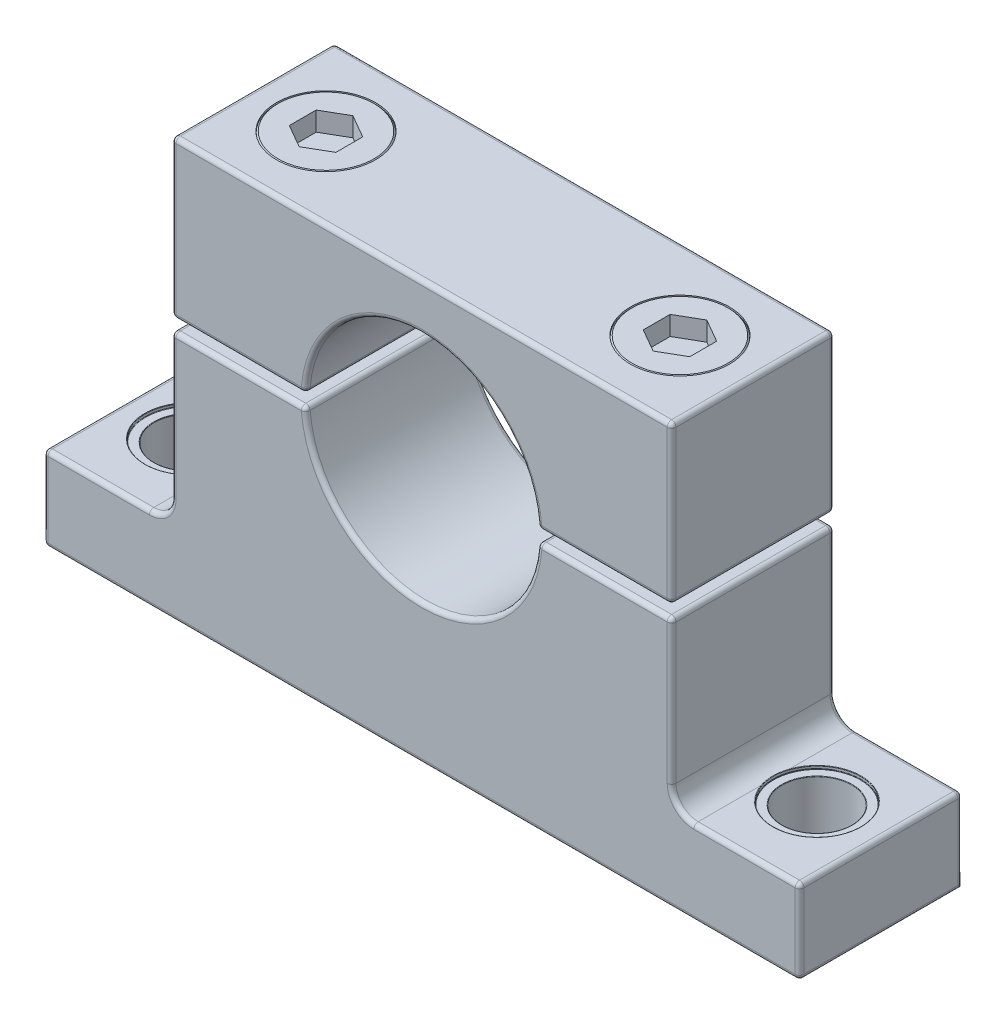
from build123d import *

# Parameters (mm, degrees)
BOSS_EXTRUDE1_DEPTH   = 14
BOSS_EXTRUDE1_2_DEPTH = 14
SKETCH4_R             = 3
CUT_EXTRUDE1_DEPTH    = 37
SKETCH8_R             = 3.762
CUT_EXTRUDE3_DEPTH    = 14.546
SKETCH10_R            = 2.754
CUT_EXTRUDE4_DEPTH    = 37
SKETCH12_R            = 4.2625
CUT_EXTRUDE5_DEPTH    = 5.015
CHAMFER1_SIZE         = 0.127
CUT_EXTRUDE6_DEPTH    = 1.65
FILLET1_R             = 0.381
FILLET2_R             = 0.381
FILLET3_R             = 0.0381


with BuildPart() as part:
    # Sketch3 → Boss-Extrude1 (new body)
    with BuildSketch(Plane.XY):
        with BuildLine():
            Line((-21.5, 36), (21.5, 36))
            Line((21.5, 36), (21.5, 22.508))
            Line((21.5, 22.508), (9.987088465, 22.508))
            ThreePointArc((9.987088465, 22.508), (0, 32), (-9.987088465, 22.508))
            Line((-9.987088465, 22.508), (-21.5, 22.508))
            Line((-21.5, 22.508), (-21.5, 36))
        make_face()
    extrude(amount=-BOSS_EXTRUDE1_DEPTH)


with BuildPart() as body_2:
    # Sketch3 → Boss-Extrude1 2 (new body)
    with BuildSketch(Plane.XY):
        with BuildLine():
            Line((-21.5, 21.492), (-21.5, 9.105))
            ThreePointArc((-21.5, 9.105), (-22.057961582, 7.757961582), (-23.405, 7.2))
            Line((-23.405, 7.2), (-32.5, 7.2))
            Line((-32.5, 7.2), (-32.5, 0))
            Line((-32.5, 0), (32.5, 0))
            Line((32.5, 0), (32.5, 7.2))
            Line((32.5, 7.2), (23.405, 7.2))
            ThreePointArc((23.405, 7.2), (22.057961582, 7.757961582), (21.5, 9.105))
            Line((21.5, 9.105), (21.5, 21.492))
            Line((21.5, 21.492), (9.987088465, 21.492))
            ThreePointArc((9.987088465, 21.492), (0, 12), (-9.987088465, 21.492))
            Line((-9.987088465, 21.492), (-21.5, 21.492))
        make_face()
    extrude(amount=-BOSS_EXTRUDE1_2_DEPTH)

    # Sketch4 → Cut-Extrude1 (cut, through all)
    with BuildSketch(Plane.XZ):
        with Locations((-27, -7)):
            Circle(SKETCH4_R)
        with Locations((27, -7)):
            Circle(SKETCH4_R)
    extrude(amount=-CUT_EXTRUDE1_DEPTH, mode=Mode.SUBTRACT)

    # Sketch8 → Cut-Extrude3 (cut)
    with BuildSketch(Plane(origin=(0, 21.492, 0), x_dir=(1, 0, 0), z_dir=(0, 1, 0))):
        with Locations((-27, 7)):
            Circle(SKETCH8_R)
        with Locations((27, 7)):
            Circle(SKETCH8_R)
    extrude(amount=-CUT_EXTRUDE3_DEPTH, mode=Mode.SUBTRACT)


with BuildPart() as cut_extrude4_tool:
    # Sketch10 → Cut-Extrude4 (new body, through all)
    with BuildSketch(Plane(origin=(0, 36, 0), x_dir=(1, 0, 0), z_dir=(0, 1, 0))):
        with Locations((15.218, 7)):
            Circle(SKETCH10_R)
        with Locations((-15.218, 7)):
            Circle(SKETCH10_R)
    extrude(amount=-CUT_EXTRUDE4_DEPTH)


with BuildPart() as part_1:
    add(part.part)

    # Cut-Extrude4: cut by cut_extrude4_tool
    add(cut_extrude4_tool.part, mode=Mode.SUBTRACT)

    # Sketch12 → Cut-Extrude5 (cut)
    with BuildSketch(Plane(origin=(0, 36, 0), x_dir=(1, 0, 0), z_dir=(0, 1, 0))):
        with Locations((15.218, 7)):
            Circle(SKETCH12_R)
        with Locations((-15.218, 7)):
            Circle(SKETCH12_R)
    extrude(amount=-CUT_EXTRUDE5_DEPTH, mode=Mode.SUBTRACT)

    # Fillet1
    fillet1_edges = [part_1.edges().sort_by_distance(p)[0] for p in [
        (0, 32, -14),
        (-21.5, 36, -7),
        (21.5, 36, -7),
        (21.5, 22.508, -7),
        (9.987088465, 22.508, -7),
        (-9.987088465, 22.508, -7),
        (-21.5, 22.508, -7),
        (15.743544232, 22.508, -14),
        (21.5, 29.254, -14),
        (0, 36, -14),
        (-21.5, 29.254, -14),
        (0, 36, 0),
        (21.5, 29.254, 0),
        (15.743544232, 22.508, 0),
        (-15.743544232, 22.508, -14),
        (0, 32, 0),
        (-15.743544232, 22.508, 0),
        (-21.5, 29.254, 0),
    ]]
    fillet(fillet1_edges, radius=FILLET1_R)


with BuildPart() as body_2_1:
    add(body_2.part)

    # Cut-Extrude4: cut by cut_extrude4_tool
    add(cut_extrude4_tool.part, mode=Mode.SUBTRACT)

    # Fillet2
    fillet2_edges = [body_2_1.edges().sort_by_distance(p)[0] for p in [
        (-22.057961582, 7.757961582, -14),
        (0, 12, 0),
        (15.743544232, 21.492, 0),
        (21.5, 15.2985, 0),
        (22.057961582, 7.757961582, 0),
        (27.9525, 7.2, 0),
        (32.5, 3.6, 0),
        (-27.9525, 7.2, -14),
        (0, 0, 0),
        (-32.5, 3.6, 0),
        (-27.9525, 7.2, 0),
        (-22.057961582, 7.757961582, 0),
        (-21.5, 15.2985, 0),
        (-15.743544232, 21.492, 0),
        (-32.5, 3.6, -14),
        (-9.987088465, 21.492, -7),
        (9.987088465, 21.492, -7),
        (21.5, 21.492, -7),
        (32.5, 7.2, -7),
        (32.5, 0, -7),
        (-32.5, 0, -7),
        (-32.5, 7.2, -7),
        (-21.5, 21.492, -7),
        (32.5, 3.6, -14),
        (27.9525, 7.2, -14),
        (22.057961582, 7.757961582, -14),
        (21.5, 15.2985, -14),
        (15.743544232, 21.492, -14),
        (0, 12, -14),
        (-15.743544232, 21.492, -14),
        (-21.5, 15.2985, -14),
    ]]
    fillet(fillet2_edges, radius=FILLET2_R)

    # Fillet3
    fillet3_edges = [body_2_1.edges().sort_by_distance(p)[0] for p in [
        (-23.279984701, 7.20410648, -7.56047317),
        (-30.762, 7.2, -7),
        (-30.762, 6.946, -7),
        (-30, 6.946, -7),
        (27.560470338, 7.2, -3.279984274),
        (23.238, 7.207334065, -7),
        (24, 6.946, -7),
        (23.238, 6.946, -7),
    ]]
    fillet(fillet3_edges, radius=FILLET3_R)


with BuildPart() as body_3:
    # Sketch15 → Revolve1 (revolve)
    with BuildSketch(Plane.XY.offset(-7)):
        Polygon((-15.218, 6.946), (-15.218, 36), (-19.468, 36), (-19.468, 31), (-17.718, 31), (-17.718, 6.946), align=None)
    revolve(axis=Axis((-15.218, 6.946, -7), (0, 1, 0)))

    # Chamfer1
    chamfer1_edges = [body_3.edges().sort_by_distance(p)[0] for p in [
        (-10.968, 36, -7),
    ]]
    chamfer(chamfer1_edges, length=CHAMFER1_SIZE)

    # Sketch16 → Cut-Extrude6 (cut)
    with BuildSketch(Plane(origin=(0, 36, 0), x_dir=(1, 0, 0), z_dir=(0, 1, 0))):
        Polygon((-15.218, 9.309401077), (-17.218, 8.154700538), (-17.218, 5.845299462), (-15.218, 4.690598923), (-13.218, 5.845299462), (-13.218, 8.154700538), align=None)
    extrude(amount=-CUT_EXTRUDE6_DEPTH, mode=Mode.SUBTRACT)


with BuildPart() as body_4:
    # Mirror1: mirrored copy
    add(body_3.part.mirror(Plane(origin=(0, 0, 0), x_dir=(0, 0, 1), z_dir=(1, 0, 0))))


solid = Compound([part_1.part, body_2_1.part, body_3.part, body_4.part])
